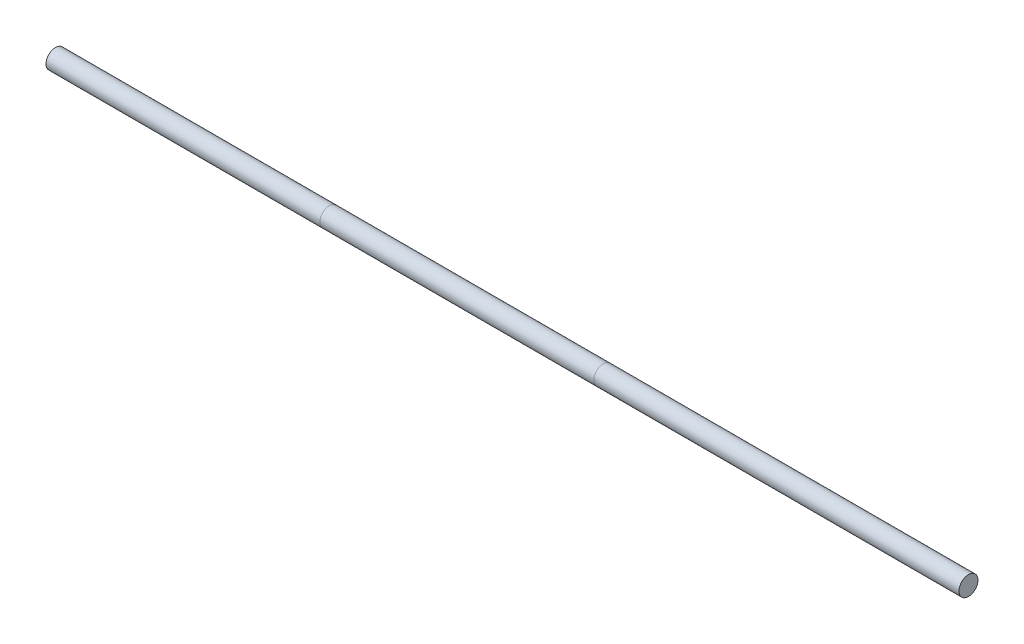
from build123d import *

# Parameters (mm, degrees)
SKETCH2_R           = 31.75
BOSS_EXTRUDE1_DEPTH = 914.4
BOSS_EXTRUDE2_START = 914.4
SKETCH2_2_R         = 31.75
BOSS_EXTRUDE2_DEPTH = 914.4
BOSS_EXTRUDE3_START = 1828.8
SKETCH2_4_R         = 31.75
BOSS_EXTRUDE3_DEPTH = 1219.2


with BuildPart() as part:
    # Sketch2 → Boss-Extrude1 (new body)
    with BuildSketch(Plane(origin=(0, 0, 0), x_dir=(0, 0, -1), z_dir=(1, 0, 0))):
        Circle(SKETCH2_R)
    extrude(amount=BOSS_EXTRUDE1_DEPTH)


with BuildPart() as body_2:
    # Sketch2_2 → Boss-Extrude2 (new body)
    with BuildSketch(Plane(origin=(0, 0, 0), x_dir=(0, 0, -1), z_dir=(1, 0, 0)).offset(BOSS_EXTRUDE2_START)):
        Circle(SKETCH2_2_R)
    extrude(amount=BOSS_EXTRUDE2_DEPTH)


with BuildPart() as body_3:
    # Sketch2_4 → Boss-Extrude3 (new body)
    with BuildSketch(Plane(origin=(0, 0, 0), x_dir=(0, 0, -1), z_dir=(1, 0, 0)).offset(BOSS_EXTRUDE3_START)):
        Circle(SKETCH2_4_R)
    extrude(amount=BOSS_EXTRUDE3_DEPTH)


solid = Compound([part.part, body_2.part, body_3.part])
